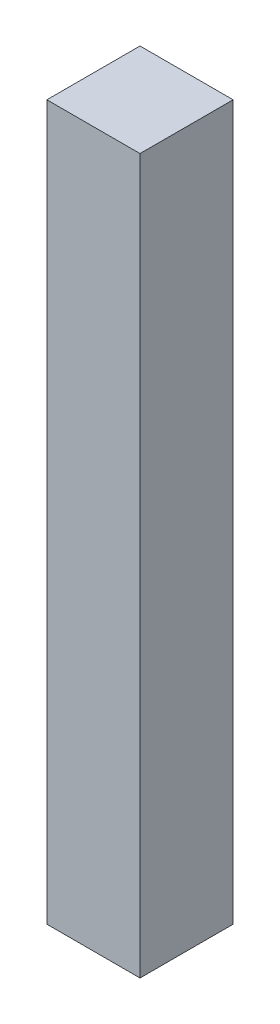
from build123d import *

# Parameters (mm, degrees)
SKETCH1_W           = 30
SKETCH1_H           = 30
BOSS_EXTRUDE1_DEPTH = 115


with BuildPart() as part:
    # Sketch1 → Boss-Extrude1 (new body, symmetric)
    with BuildSketch(Plane(origin=(0, 0, 0), x_dir=(1, 0, 0), z_dir=(0, 1, 0))):
        Rectangle(SKETCH1_W, SKETCH1_H)
    extrude(amount=BOSS_EXTRUDE1_DEPTH, both=True)


solid = part.part
